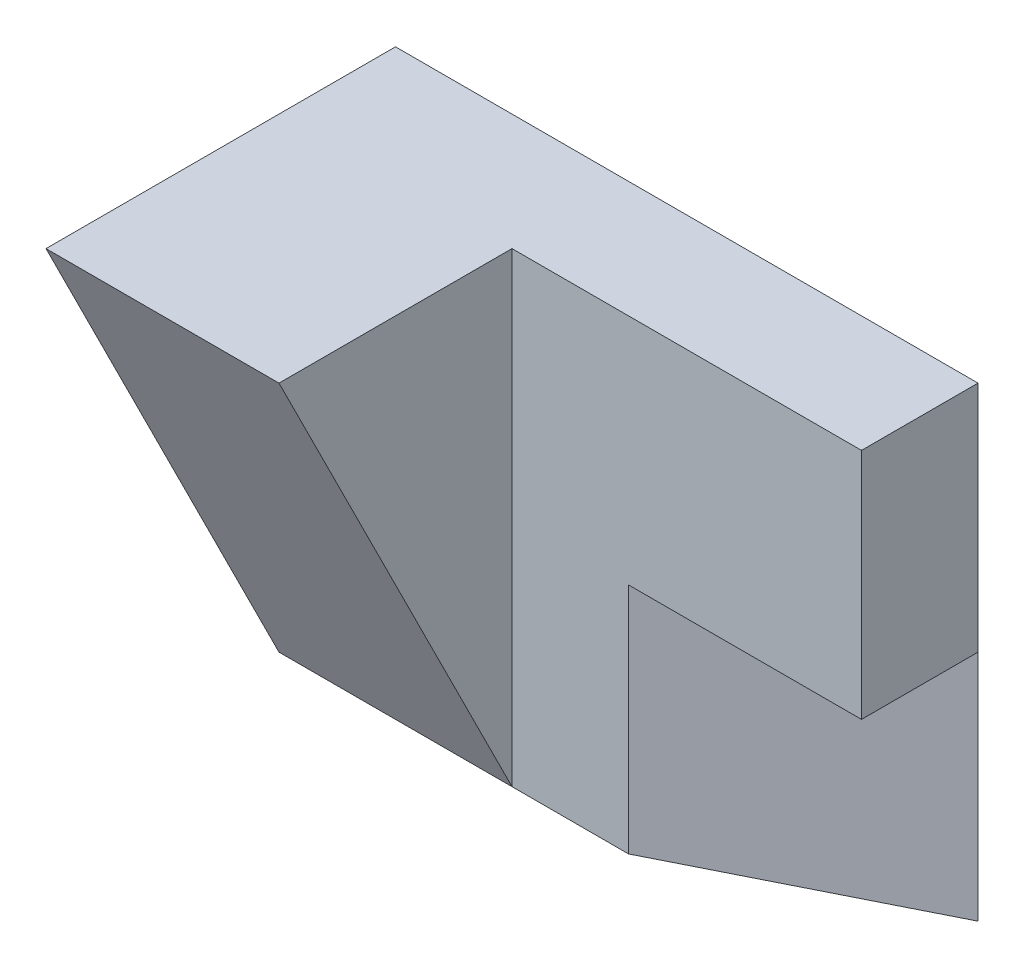
from build123d import *

# Parameters (mm, degrees)
SKETCH1_W           = 40
SKETCH1_H           = 50
BOSS_EXTRUDE1_DEPTH = 10
CUT_EXTRUDE1_DEPTH  = 20
SKETCH3_W           = 20
SKETCH3_H           = 40
BOSS_EXTRUDE2_DEPTH = 20
CUT_EXTRUDE2_DEPTH  = 20


with BuildPart() as part:
    # Sketch1 → Boss-Extrude1 (new body)
    with BuildSketch(Plane(origin=(0, 0, 0), x_dir=(0, 1, 0), z_dir=(0, 0, 1))):
        with Locations((20, 25)):
            Rectangle(SKETCH1_W, SKETCH1_H)
    extrude(amount=BOSS_EXTRUDE1_DEPTH)

    # Sketch2 → Cut-Extrude1 (cut)
    with BuildSketch(Plane.XZ):
        Polygon((0, 10), (-20, 10), (0, 0), align=None)
    extrude(amount=-CUT_EXTRUDE1_DEPTH, mode=Mode.SUBTRACT)

    # Sketch3 → Boss-Extrude2 (add)
    with BuildSketch(Plane.XY.offset(10)):
        with Locations((-40, 20)):
            Rectangle(SKETCH3_W, SKETCH3_H)
    extrude(amount=BOSS_EXTRUDE2_DEPTH)

    # Sketch4 → Cut-Extrude2 (cut)
    with BuildSketch(Plane.YZ.offset(-30)):
        Polygon((0, 10), (40, 30), (0, 30), align=None)
    extrude(amount=-CUT_EXTRUDE2_DEPTH, mode=Mode.SUBTRACT)


solid = part.part
